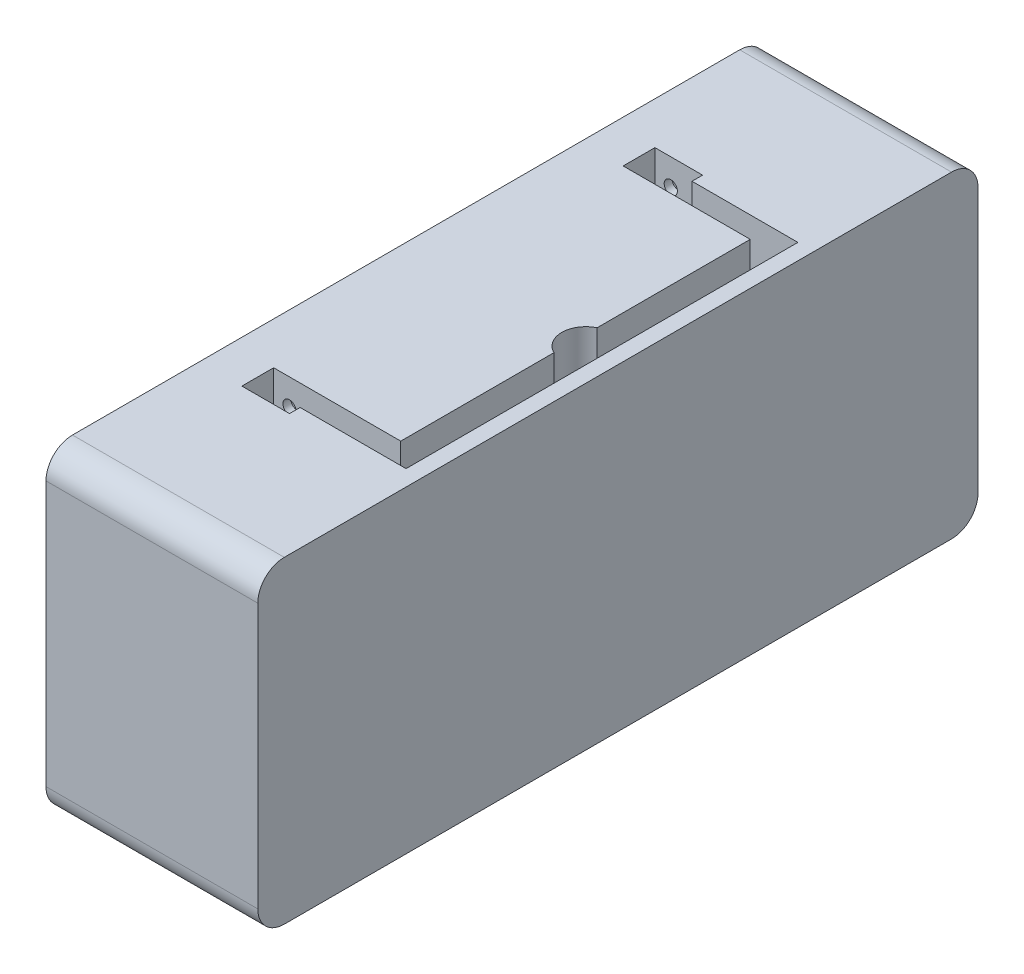
from build123d import *

# Parameters (mm, degrees)
BOSS_EXTRUDE1_DEPTH = 40
CUT_EXTRUDE1_DEPTH  = 10
CUT_EXTRUDE2_START  = -1.5
SKETCH5_R           = 1.25
CUT_EXTRUDE2_DEPTH  = 9


with BuildPart() as part:
    # Sketch1 → Boss-Extrude1 (new body)
    with BuildSketch(Plane(origin=(0, 0, 0), x_dir=(0, 0, -1), z_dir=(1, 0, 0))):
        with BuildLine():
            Line((-63, -30), (63, -30))
            ThreePointArc((63, -30), (66.535533906, -28.535533906), (68, -25))
            Line((68, -25), (68, 25))
            ThreePointArc((68, 25), (66.535533906, 28.535533906), (63, 30))
            Line((63, 30), (-63, 30))
            ThreePointArc((-63, 30), (-66.535533906, 28.535533906), (-68, 25))
            Line((-68, 25), (-68, -25))
            ThreePointArc((-68, -25), (-66.535533906, -28.535533906), (-63, -30))
        make_face()
    extrude(amount=-BOSS_EXTRUDE1_DEPTH)

    # Sketch3 → Cut-Extrude1 (cut)
    with BuildSketch(Plane(origin=(0, 30, 0), x_dir=(1, 0, 0), z_dir=(0, 1, 0))):
        with BuildLine():
            Line((-3.009553383, -37), (-23.009553383, -37))
            Line((-23.009553383, -37), (-23.009553383, -39))
            Line((-23.009553383, -39), (-32.009553383, -39))
            Line((-32.009553383, -39), (-32.009553383, -33))
            Line((-32.009553383, -33), (-8.009553383, -33))
            Line((-8.009553383, -33), (-8.009553383, -4.067313184))
            ThreePointArc((-8.009553383, -4.067313184), (-10.584205762, 0), (-8.009553383, 4.067313184))
            Line((-8.009553383, 4.067313184), (-8.009553383, 33))
            Line((-8.009553383, 33), (-32.009553383, 33))
            Line((-32.009553383, 33), (-32.009553383, 39))
            Line((-32.009553383, 39), (-23.009553383, 39))
            Line((-23.009553383, 39), (-23.009553383, 37))
            Line((-23.009553383, 37), (-3.009553383, 37))
            Line((-3.009553383, 37), (-3.009553383, -37))
        make_face()
    extrude(amount=-CUT_EXTRUDE1_DEPTH, mode=Mode.SUBTRACT)

    # Sketch5 → Cut-Extrude2 (cut)
    with BuildSketch(Plane.XY.offset(-39).offset(CUT_EXTRUDE2_START)):
        with Locations((-29.012566775, 25)):
            Circle(SKETCH5_R)
    cut_extrude2 = extrude(amount=CUT_EXTRUDE2_DEPTH, mode=Mode.SUBTRACT)

    # Mirror1: Cut-Extrude2 across plane
    add(cut_extrude2.mirror(Plane.XY), mode=Mode.SUBTRACT)


solid = part.part
